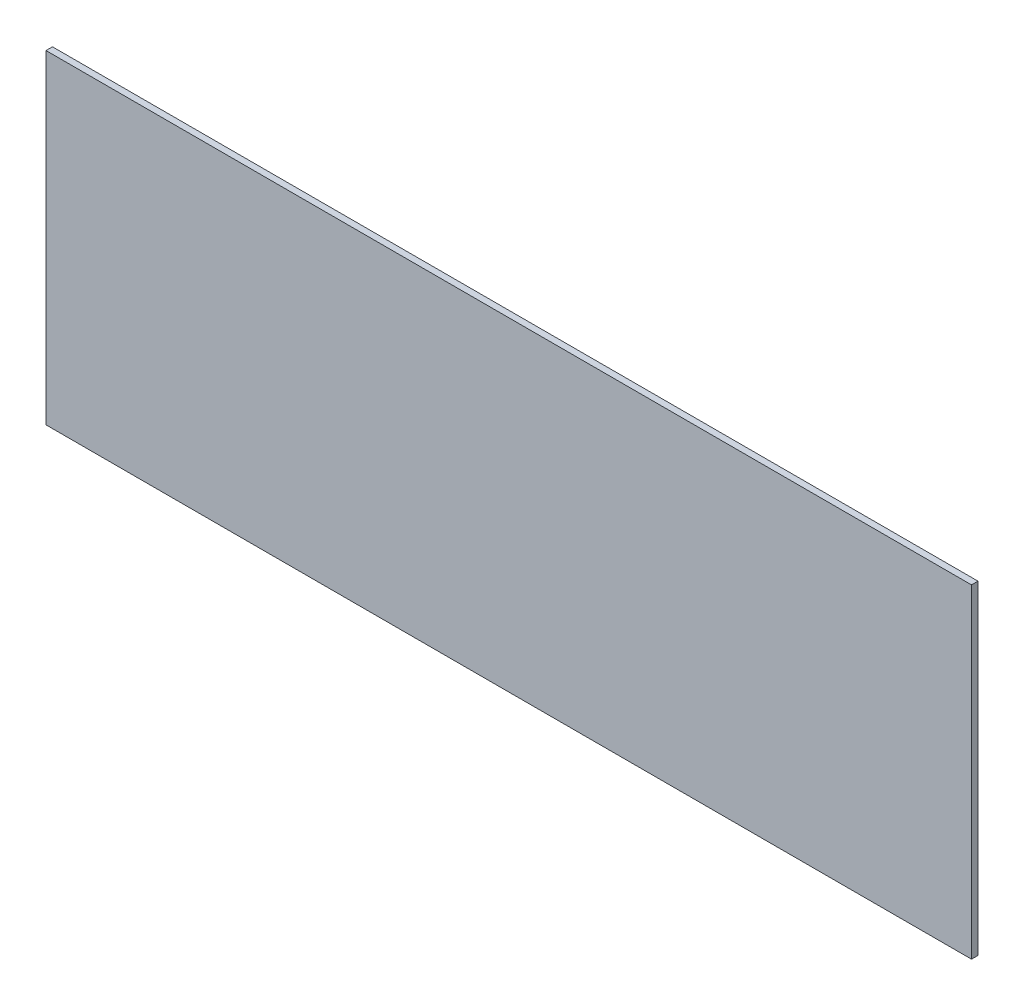
from build123d import *

# Parameters (mm, degrees)
SKETCH1_W           = 285.5
SKETCH1_H           = 100
BOSS_EXTRUDE1_DEPTH = 2


with BuildPart() as part:
    # Sketch1 → Boss-Extrude1 (new body)
    with BuildSketch(Plane.XY):
        Rectangle(SKETCH1_W, SKETCH1_H)
    extrude(amount=BOSS_EXTRUDE1_DEPTH)


solid = part.part
